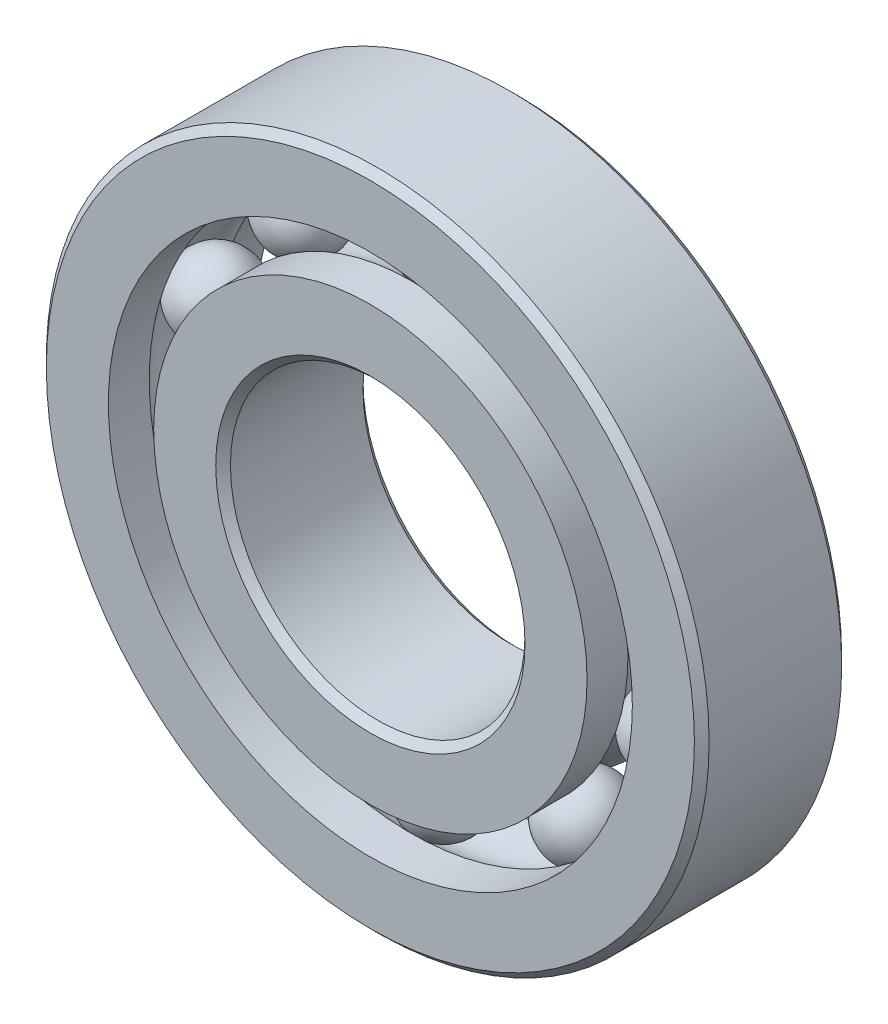
from build123d import *

# Parameters (mm, degrees)
CIRPATTERN1_COUNT = 10


with BuildPart() as part:
    # Sketch1 → Revolve1 (revolve)
    with BuildSketch(Plane(origin=(0, 0, 0), x_dir=(0, 0, -1), z_dir=(1, 0, 0))):
        with BuildLine():
            Line((2.8575, 14.2875), (-2.8575, 14.2875))
            Line((-2.8575, 14.2875), (-3.175, 13.97))
            Line((-3.175, 13.97), (-3.175, 11.295673077))
            Line((-3.175, 11.295673077), (-1.411111111, 11.295673077))
            ThreePointArc((-1.411111111, 11.295673077), (0, 12.035028901), (1.411111111, 11.295673077))
            Line((1.411111111, 11.295673077), (3.175, 11.295673077))
            Line((3.175, 11.295673077), (3.175, 13.97))
            Line((3.175, 13.97), (2.8575, 14.2875))
        make_face()
    revolve(axis=Axis((0, 0, 3.175), (0, 0, -1)))


with BuildPart() as body_2:
    # Sketch3 → Revolve3 (revolve)
    with BuildSketch(Plane(origin=(0, 0, 0), x_dir=(0, 0, -1), z_dir=(1, 0, 0))):
        with BuildLine():
            Line((-3.175, 9.341826923), (-1.411111111, 9.341826923))
            ThreePointArc((-1.411111111, 9.341826923), (0, 8.602471099), (1.411111111, 9.341826923))
            Line((1.411111111, 9.341826923), (3.175, 9.341826923))
            Line((3.175, 9.341826923), (3.175, 6.6675))
            Line((3.175, 6.6675), (2.8575, 6.35))
            Line((2.8575, 6.35), (-2.8575, 6.35))
            Line((-2.8575, 6.35), (-3.175, 6.6675))
            Line((-3.175, 6.6675), (-3.175, 9.341826923))
        make_face()
    revolve(axis=Axis((0, 0, 3.175), (0, 0, -1)))


with BuildPart() as body_3:
    # Sketch4 → Revolve4 (revolve)
    with BuildSketch(Plane(origin=(0, 0, 0), x_dir=(0, 0, -1), z_dir=(1, 0, 0))):
        with BuildLine():
            Line((-1.716278901, 10.31875), (1.716278901, 10.31875))
            ThreePointArc((1.716278901, 10.31875), (0, 12.035028901), (-1.716278901, 10.31875))
        make_face()
    revolve(axis=Axis((0, 10.31875, 1.716278901), (0, 0, -1)))


with BuildPart() as cirpattern1_1:
    # CirPattern1: pattern copy
    add(body_3.part.rotate(Axis((0, 0, -3.175), (0, 0, 1)), 1 * 360 / CIRPATTERN1_COUNT))


with BuildPart() as cirpattern1_2:
    # CirPattern1: pattern copy
    add(body_3.part.rotate(Axis((0, 0, -3.175), (0, 0, 1)), 2 * 360 / CIRPATTERN1_COUNT))


with BuildPart() as cirpattern1_3:
    # CirPattern1: pattern copy
    add(body_3.part.rotate(Axis((0, 0, -3.175), (0, 0, 1)), 3 * 360 / CIRPATTERN1_COUNT))


with BuildPart() as cirpattern1_4:
    # CirPattern1: pattern copy
    add(body_3.part.rotate(Axis((0, 0, -3.175), (0, 0, 1)), 4 * 360 / CIRPATTERN1_COUNT))


with BuildPart() as cirpattern1_5:
    # CirPattern1: pattern copy
    add(body_3.part.rotate(Axis((0, 0, -3.175), (0, 0, 1)), 5 * 360 / CIRPATTERN1_COUNT))


with BuildPart() as cirpattern1_6:
    # CirPattern1: pattern copy
    add(body_3.part.rotate(Axis((0, 0, -3.175), (0, 0, 1)), 6 * 360 / CIRPATTERN1_COUNT))


with BuildPart() as cirpattern1_7:
    # CirPattern1: pattern copy
    add(body_3.part.rotate(Axis((0, 0, -3.175), (0, 0, 1)), 7 * 360 / CIRPATTERN1_COUNT))


with BuildPart() as cirpattern1_8:
    # CirPattern1: pattern copy
    add(body_3.part.rotate(Axis((0, 0, -3.175), (0, 0, 1)), 8 * 360 / CIRPATTERN1_COUNT))


with BuildPart() as cirpattern1_9:
    # CirPattern1: pattern copy
    add(body_3.part.rotate(Axis((0, 0, -3.175), (0, 0, 1)), 9 * 360 / CIRPATTERN1_COUNT))


solid = Compound([part.part, body_2.part, body_3.part, cirpattern1_1.part, cirpattern1_2.part, cirpattern1_3.part, cirpattern1_4.part, cirpattern1_5.part, cirpattern1_6.part, cirpattern1_7.part, cirpattern1_8.part, cirpattern1_9.part])
